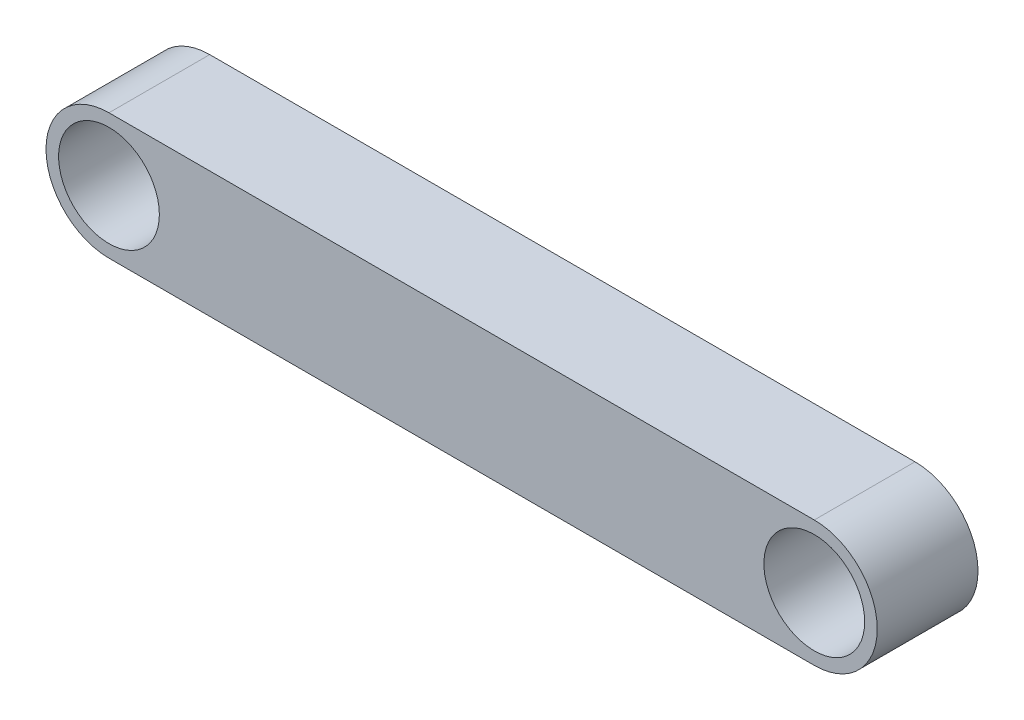
from build123d import *

# Parameters (mm, degrees)
SKETCH3_R           = 10
BOSS_EXTRUDE2_DEPTH = 10


with BuildPart() as part:
    # Sketch3 → Boss-Extrude2 (new body, symmetric)
    with BuildSketch(Plane.XY):
        with BuildLine():
            Line((0, 12.5), (140, 12.5))
            ThreePointArc((140, 12.5), (152.5, 0), (140, -12.5))
            Line((140, -12.5), (0, -12.5))
            ThreePointArc((0, -12.5), (-12.5, 0), (0, 12.5))
        make_face()
        Circle(SKETCH3_R, mode=Mode.SUBTRACT)
        with Locations((140, 0)):
            Circle(SKETCH3_R, mode=Mode.SUBTRACT)
    extrude(amount=BOSS_EXTRUDE2_DEPTH, both=True)


solid = part.part
